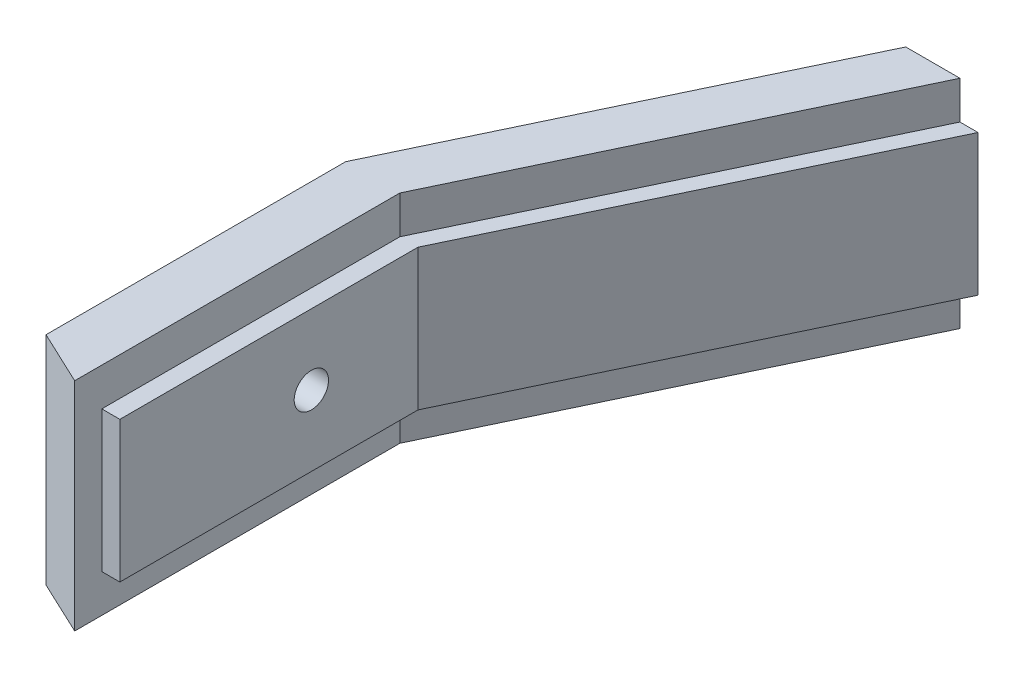
from build123d import *

# Parameters (mm, degrees)
SKETCH1_W           = 16.5
SKETCH1_H           = 7.8
BOSS_EXTRUDE1_DEPTH = 1
SKETCH2_W           = 18
SKETCH2_H           = 12
BOSS_EXTRUDE2_DEPTH = 3
CUT_EXTRUDE1_DEPTH  = 12
SKETCH6_R           = 0.95
CUT_EXTRUDE2_DEPTH  = 4
SKETCH8_R           = 2.5
CUT_EXTRUDE3_DEPTH  = 2.5


with BuildPart() as part:
    # Sketch1 → Boss-Extrude1 (new body)
    with BuildSketch(Plane(origin=(0, 0, 0), x_dir=(0, 0, -1), z_dir=(1, 0, 0))):
        with Locations((-8.25, 3.9)):
            Rectangle(SKETCH1_W, SKETCH1_H)
    extrude(amount=BOSS_EXTRUDE1_DEPTH)

    # Sketch2 → Boss-Extrude2 (add)
    with BuildSketch(Plane.ZY):
        with Locations((9, 3.9)):
            Rectangle(SKETCH2_W, SKETCH2_H)
    extrude(amount=BOSS_EXTRUDE2_DEPTH)

    # Sketch3 → Loft1 section 0
    with BuildSketch(Plane(origin=(0, 0, 0), x_dir=(-1, 0, 0), z_dir=(0, 0, -1))):
        Polygon((0, 7.8), (0, 9.9), (3, 9.9), (3, -2.1), (0, -2.1), (0, 0), (-1, 0), (-1, 7.8), align=None)
    # Sketch4 → Loft1 section 1
    with BuildSketch(Plane(origin=(0, 0, -21), x_dir=(-1, 0, 0), z_dir=(0, 0, -1))):
        Polygon((-11, 7.8), (-10, 7.8), (-10, 9.9), (-7, 9.9), (-7, -2.1), (-10, -2.1), (-10, 0), (-11, 0), align=None)
    loft()

    # Sketch5 → Cut-Extrude1 (cut)
    with BuildSketch(Plane(origin=(0, 9.9, 0), x_dir=(1, 0, 0), z_dir=(0, 1, 0))):
        Polygon((0, -18), (-3, -18), (-3, -16.588307156), align=None)
    extrude(amount=-CUT_EXTRUDE1_DEPTH, mode=Mode.SUBTRACT)

    # Sketch6 → Cut-Extrude2 (cut)
    with BuildSketch(Plane(origin=(1, 0, 0), x_dir=(0, 0, -1), z_dir=(1, 0, 0))):
        with Locations((-5.9, 3.9)):
            Circle(SKETCH6_R)
    extrude(amount=-CUT_EXTRUDE2_DEPTH, mode=Mode.SUBTRACT)

    # Sketch8 → Cut-Extrude3 (cut)
    with BuildSketch(Plane.ZY.offset(3)):
        with Locations((5.9, 3.9)):
            Circle(SKETCH8_R)
    extrude(amount=-CUT_EXTRUDE3_DEPTH, mode=Mode.SUBTRACT)


solid = part.part
